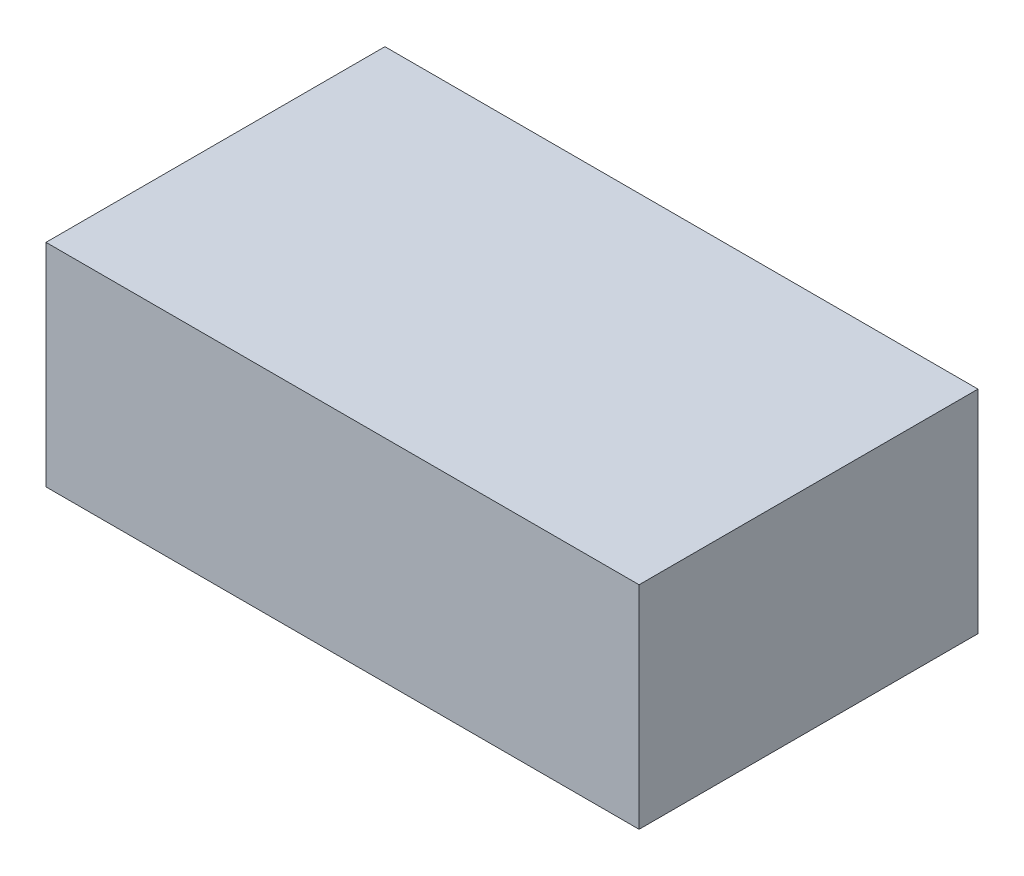
from build123d import *

# Parameters (mm, degrees)
SKETCH1_W           = 17.78
SKETCH1_H           = 6.35
BOSS_EXTRUDE1_DEPTH = 10.16


with BuildPart() as part:
    # Sketch1 → Boss-Extrude1 (new body)
    with BuildSketch(Plane.XY):
        Rectangle(SKETCH1_W, SKETCH1_H)
    extrude(amount=BOSS_EXTRUDE1_DEPTH)


solid = part.part
